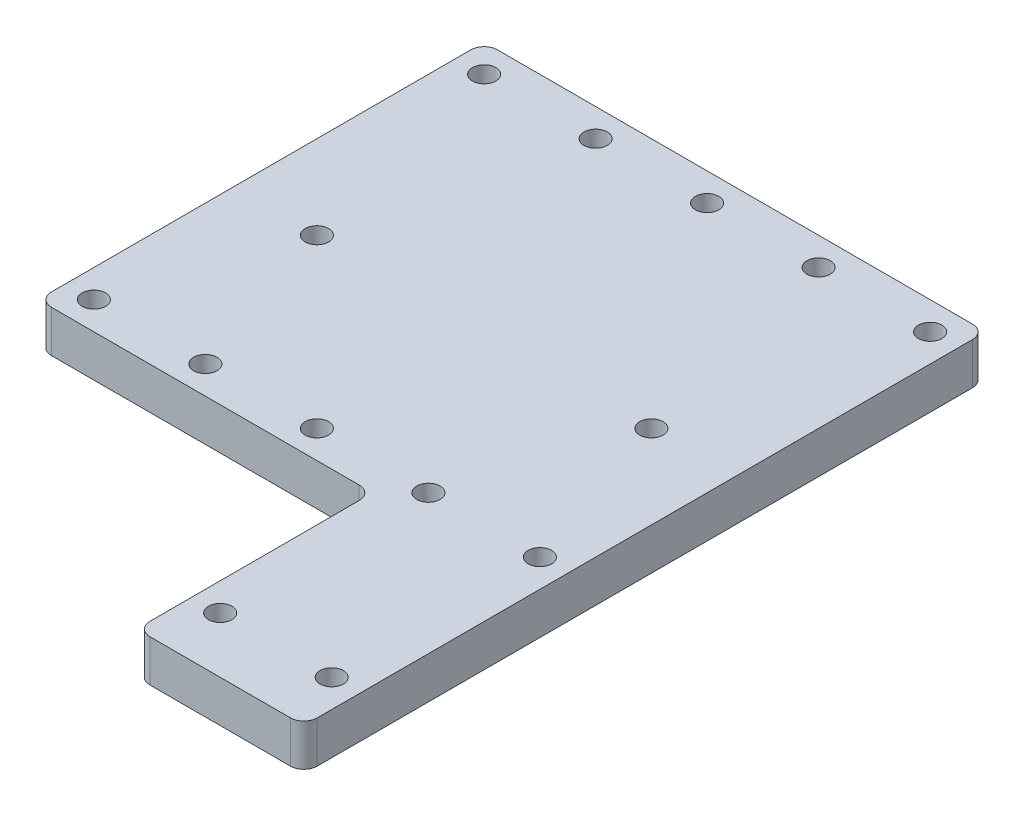
from build123d import *

# Parameters (mm, degrees)
SKETCH1_W           = 38.1
SKETCH1_H           = 156.8323
BOSS_EXTRUDE1_DEPTH = 9.525
FILLET1_R           = 3.048
FILLET2_R           = 3.048
FILLET3_R           = 3.048
SKETCH2_R           = 2.667
CUT_EXTRUDE1_DEPTH  = 25.4
CUT_EXTRUDE2_DEPTH  = 29.718
SKETCH4_R           = 2.667
BOSS_EXTRUDE2_DEPTH = 9.525
SKETCH5_R           = 2.667
CUT_EXTRUDE3_DEPTH  = 9.525


with BuildPart() as part:
    # Sketch1 → Boss-Extrude1 (new body)
    with BuildSketch(Plane(origin=(0, 0, 0), x_dir=(1, 0, 0), z_dir=(0, 1, 0))):
        Rectangle(SKETCH1_W, SKETCH1_H)
    extrude(amount=BOSS_EXTRUDE1_DEPTH)

    # Fillet1
    fillet1_edges = [part.edges().sort_by_distance(p)[0] for p in [
        (19.05, 4.7625, 78.41615),
        (-19.05, 4.7625, 78.41615),
    ]]
    fillet(fillet1_edges, radius=FILLET1_R)

    # Fillet2
    fillet2_edges = [part.edges().sort_by_distance(p)[0] for p in [
        (-19.05, 4.7625, -78.41615),
    ]]
    fillet(fillet2_edges, radius=FILLET2_R)

    # Fillet3
    fillet3_edges = [part.edges().sort_by_distance(p)[0] for p in [
        (19.05, 4.7625, -78.41615),
    ]]
    fillet(fillet3_edges, radius=FILLET3_R)

    # Sketch2 → Cut-Extrude1 (cut)
    with BuildSketch(Plane(origin=(0, 9.525, 0), x_dir=(1, 0, 0), z_dir=(0, 1, 0))):
        with Locations((12.7, 72.06615)):
            Circle(SKETCH2_R)
        with Locations((12.7, -16.83385)):
            Circle(SKETCH2_R)
        with Locations((-12.7, -16.83385)):
            Circle(SKETCH2_R)
        with Locations((-12.7, 72.06615)):
            Circle(SKETCH2_R)
        with Locations((-12.7, -64.25565)):
            Circle(SKETCH2_R)
        with Locations((12.7, -64.25565)):
            Circle(SKETCH2_R)
    extrude(amount=-CUT_EXTRUDE1_DEPTH, mode=Mode.SUBTRACT)

    # Sketch3 → Cut-Extrude2 (cut)
    with BuildSketch(Plane(origin=(0, 9.525, 0), x_dir=(1, 0, 0), z_dir=(0, 1, 0))):
        with BuildLine():
            ThreePointArc((-16.002, -76.95565), (-18.157261469, -76.062911469), (-19.05, -73.90765))
            Line((-19.05, -73.90765), (-19.05, -75.36815))
            ThreePointArc((-19.05, -75.36815), (-18.936369601, -76.19263714), (-18.603950759, -76.95565))
            Line((-18.603950759, -76.95565), (-16.002, -76.95565))
        make_face()
        with BuildLine():
            Line((-12.7, -76.95565), (-16.002, -76.95565))
            Line((-16.002, -76.95565), (-18.603950759, -76.95565))
            ThreePointArc((-18.603950759, -76.95565), (-17.493912196, -78.026063091), (-16.002, -78.41615))
            Line((-16.002, -78.41615), (16.002, -78.41615))
            ThreePointArc((16.002, -78.41615), (17.493912196, -78.026063091), (18.603950759, -76.95565))
            Line((18.603950759, -76.95565), (16.002, -76.95565))
            Line((16.002, -76.95565), (-12.7, -76.95565))
        make_face()
        with BuildLine():
            ThreePointArc((19.05, -73.90765), (18.157261469, -76.062911469), (16.002, -76.95565))
            Line((16.002, -76.95565), (18.603950759, -76.95565))
            ThreePointArc((18.603950759, -76.95565), (18.936369601, -76.19263714), (19.05, -75.36815))
            Line((19.05, -75.36815), (19.05, -73.90765))
        make_face()
    extrude(amount=-CUT_EXTRUDE2_DEPTH, mode=Mode.SUBTRACT)

    # Sketch4 → Boss-Extrude2 (add)
    with BuildSketch(Plane.XZ):
        with BuildLine():
            Line((-92.202, -78.41615), (-16.002, -78.41615))
            ThreePointArc((-16.002, -78.41615), (-18.157261469, -77.523411469), (-19.05, -75.36815))
            Line((-19.05, -75.36815), (-19.05, 26.23185))
            ThreePointArc((-19.05, 26.23185), (-19.942738531, 24.076588531), (-22.098, 23.18385))
            Line((-22.098, 23.18385), (-92.202, 23.18385))
            ThreePointArc((-92.202, 23.18385), (-94.357261469, 22.291111469), (-95.25, 20.13585))
            Line((-95.25, 20.13585), (-95.25, -75.36815))
            ThreePointArc((-95.25, -75.36815), (-94.357261469, -77.523411469), (-92.202, -78.41615))
        make_face()
        with Locations((-88.9, -72.06615)):
            Circle(SKETCH4_R, mode=Mode.SUBTRACT)
        with Locations((-63.5, -72.06615)):
            Circle(SKETCH4_R, mode=Mode.SUBTRACT)
        with Locations((-38.1, -72.06615)):
            Circle(SKETCH4_R, mode=Mode.SUBTRACT)
        with Locations((-88.9, 16.83385)):
            Circle(SKETCH4_R, mode=Mode.SUBTRACT)
        with Locations((-63.5, 16.83385)):
            Circle(SKETCH4_R, mode=Mode.SUBTRACT)
        with Locations((-38.1, 16.83385)):
            Circle(SKETCH4_R, mode=Mode.SUBTRACT)
    extrude(amount=-BOSS_EXTRUDE2_DEPTH)

    # Sketch5 → Cut-Extrude3 (cut)
    with BuildSketch(Plane.XZ):
        with Locations((0, -21.26615)):
            Circle(SKETCH5_R)
        with Locations((-76.2, -21.26615)):
            Circle(SKETCH5_R)
    extrude(amount=-CUT_EXTRUDE3_DEPTH, mode=Mode.SUBTRACT)


solid = part.part
